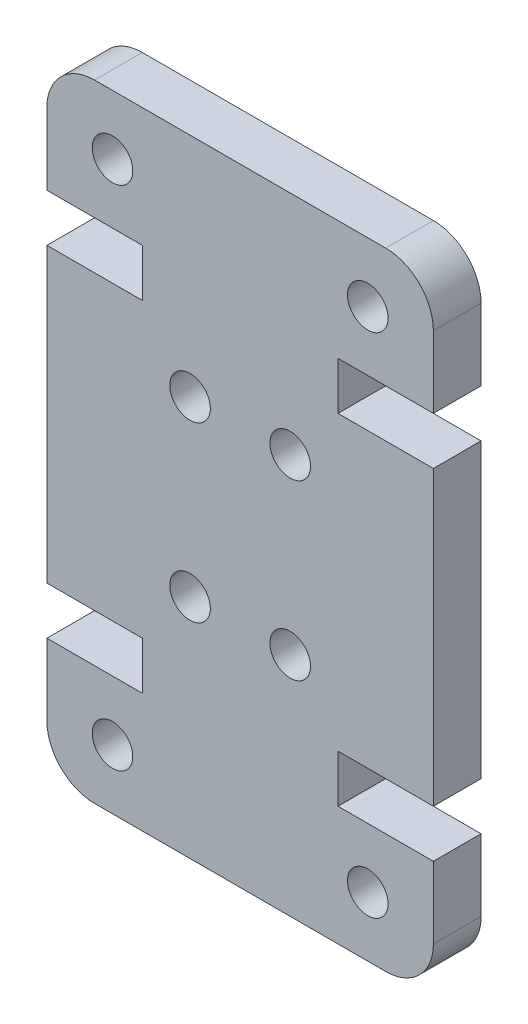
from build123d import *

# Parameters (mm, degrees)
SKETCH2_R           = 0.85
BOSS_EXTRUDE1_DEPTH = 4
SKETCH3_W           = 16.2
SKETCH3_H           = 26.26
CUT_EXTRUDE1_DEPTH  = 2


with BuildPart() as part:
    # Sketch2 → Boss-Extrude1 (new body)
    with BuildSketch(Plane.XY):
        with BuildLine():
            Line((0, 7), (0, 19.26))
            Line((0, 19.26), (4, 19.26))
            Line((4, 19.26), (4, 21.26))
            Line((4, 21.26), (0, 21.26))
            Line((0, 21.26), (0, 24.26))
            ThreePointArc((0, 24.26), (0.585786438, 25.674213562), (2, 26.26))
            Line((2, 26.26), (14.2, 26.26))
            ThreePointArc((14.2, 26.26), (15.614213562, 25.674213562), (16.2, 24.26))
            Line((16.2, 24.26), (16.2, 21.26))
            Line((16.2, 21.26), (12.2, 21.26))
            Line((12.2, 21.26), (12.2, 19.26))
            Line((12.2, 19.26), (16.2, 19.26))
            Line((16.2, 19.26), (16.2, 7))
            Line((16.2, 7), (12.2, 7))
            Line((12.2, 7), (12.2, 5))
            Line((12.2, 5), (16.2, 5))
            Line((16.2, 5), (16.2, 2))
            ThreePointArc((16.2, 2), (15.614213562, 0.585786438), (14.2, 0))
            Line((14.2, 0), (2, 0))
            ThreePointArc((2, 0), (0.585786438, 0.585786438), (0, 2))
            Line((0, 2), (0, 5))
            Line((0, 5), (4, 5))
            Line((4, 5), (4, 7))
            Line((4, 7), (0, 7))
        make_face()
        with Locations((13.45, 2.5)):
            Circle(SKETCH2_R, mode=Mode.SUBTRACT)
        with Locations((10.2, 9.5)):
            Circle(SKETCH2_R, mode=Mode.SUBTRACT)
        with Locations((2.75, 23.76)):
            Circle(SKETCH2_R, mode=Mode.SUBTRACT)
        with Locations((6, 16.76)):
            Circle(SKETCH2_R, mode=Mode.SUBTRACT)
        with Locations((10.2, 16.76)):
            Circle(SKETCH2_R, mode=Mode.SUBTRACT)
        with Locations((13.45, 23.76)):
            Circle(SKETCH2_R, mode=Mode.SUBTRACT)
        with Locations((6, 9.5)):
            Circle(SKETCH2_R, mode=Mode.SUBTRACT)
        with Locations((2.75, 2.5)):
            Circle(SKETCH2_R, mode=Mode.SUBTRACT)
    extrude(amount=BOSS_EXTRUDE1_DEPTH)

    # Sketch3 → Cut-Extrude1 (cut)
    with BuildSketch(Plane.XY.offset(4)):
        with Locations((8.1, 13.13)):
            Rectangle(SKETCH3_W, SKETCH3_H)
    extrude(amount=-CUT_EXTRUDE1_DEPTH, mode=Mode.SUBTRACT)


solid = part.part
